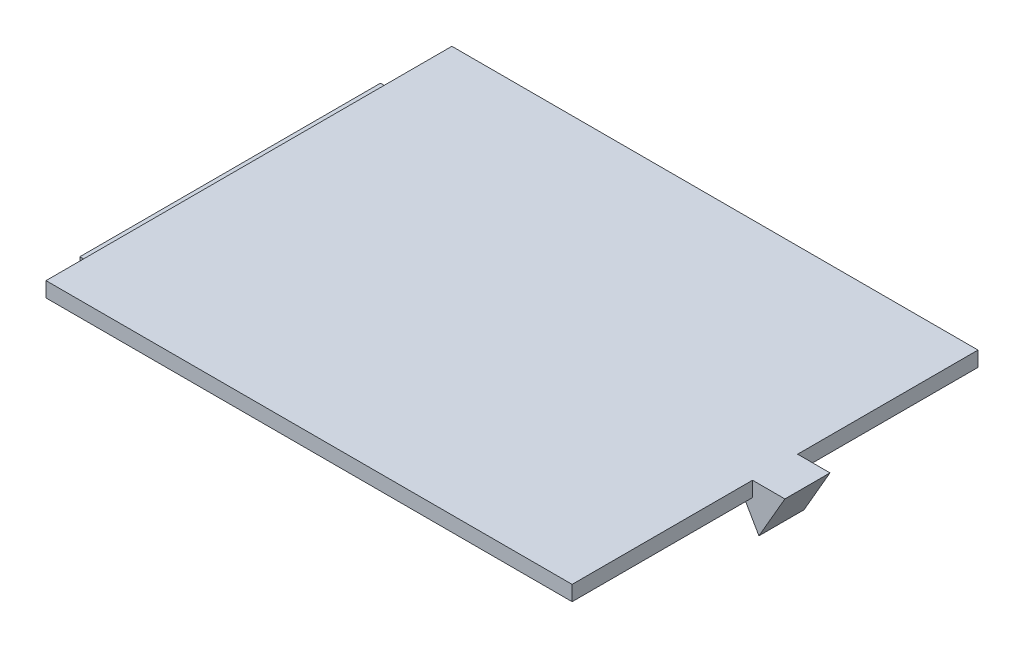
from build123d import *

# Parameters (mm, degrees)
SKETCH1_W           = 70
SKETCH1_H           = 54
BOSS_EXTRUDE1_DEPTH = 2
SKETCH2_W           = 5
SKETCH2_H           = 40
BOSS_EXTRUDE2_DEPTH = 1
BOSS_EXTRUDE3_START = -24
BOSS_EXTRUDE3_DEPTH = 6


with BuildPart() as part:
    # Sketch1 → Boss-Extrude1 (new body)
    with BuildSketch(Plane(origin=(0, 0, 0), x_dir=(1, 0, 0), z_dir=(0, 1, 0))):
        Rectangle(SKETCH1_W, SKETCH1_H)
    extrude(amount=BOSS_EXTRUDE1_DEPTH)

    # Sketch2 → Boss-Extrude2 (add)
    with BuildSketch(Plane.XZ):
        with Locations((-35, 0)):
            Rectangle(SKETCH2_W, SKETCH2_H)
    extrude(amount=BOSS_EXTRUDE2_DEPTH)

    # Sketch3 → Boss-Extrude3 (add)
    with BuildSketch(Plane.XY.offset(27).offset(BOSS_EXTRUDE3_START)):
        Polygon((35.85458287, -3.981493023), (39.307999477, 2), (32.401166263, 2), align=None)
    extrude(amount=-BOSS_EXTRUDE3_DEPTH)


solid = part.part
